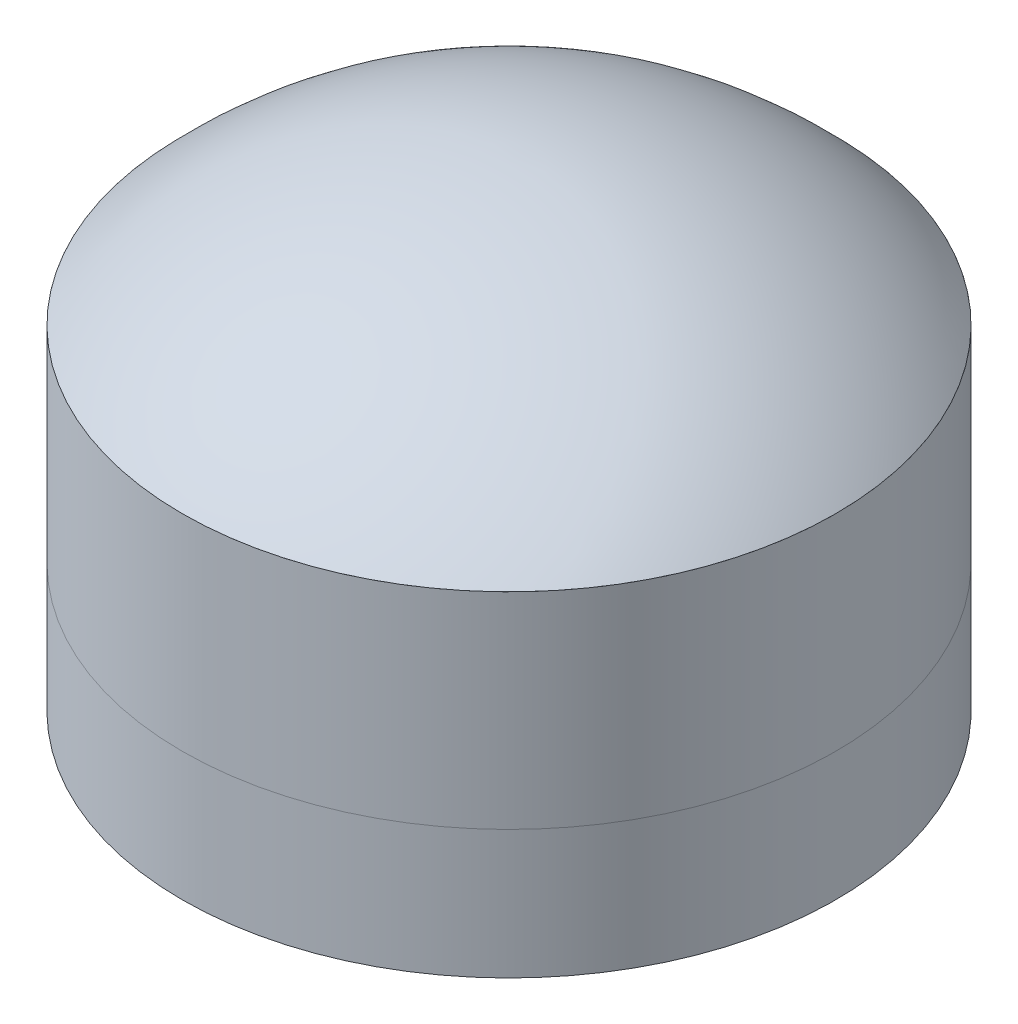
from build123d import *

# Parameters (mm, degrees)
SKETCH1_R           = 6.35
BOSS_EXTRUDE1_DEPTH = 2.5
SKETCH2_R           = 6.35
BOSS_EXTRUDE2_DEPTH = 4


with BuildPart() as part:
    # Sketch1 → Boss-Extrude1 (new body)
    with BuildSketch(Plane(origin=(0, 0, 0), x_dir=(1, 0, 0), z_dir=(0, 1, 0))):
        with Locations(Location((0, 0, 0), (0, 0, 270))):  # turned: the seam where the file's is
            Circle(SKETCH1_R)
    extrude(amount=BOSS_EXTRUDE1_DEPTH)


with BuildPart() as body_2:
    # Sketch2 → Boss-Extrude2 (new body)
    with BuildSketch(Plane(origin=(0, 2.5, 0), x_dir=(1, 0, 0), z_dir=(0, 1, 0))):
        with Locations(Location((0, 0, 0), (0, 0, 270))):  # turned: the seam where the file's is
            Circle(SKETCH2_R)
    extrude(amount=BOSS_EXTRUDE2_DEPTH)


with BuildPart() as body_3:
    # Sketch3 → Revolve1 (revolve)
    with BuildSketch(Plane.XY, mode=Mode.PRIVATE) as revolve1_sk:
        with BuildLine():
            Line((6.35, 6.5), (0, 6.5))
            Line((0, 6.5), (0, 9.23627495))
            ThreePointArc((0, 9.23627495), (3.457227958, 8.523096338), (6.35, 6.5))
        make_face()
    revolve(revolve1_sk.sketch.rotate(Axis((0, 8.421453096, 0), (0, -1, 0)), 90), axis=Axis((0, 8.421453096, 0), (0, -1, 0)))  # turned: the seam where the file's is


solid = Compound([part.part, body_2.part, body_3.part])
